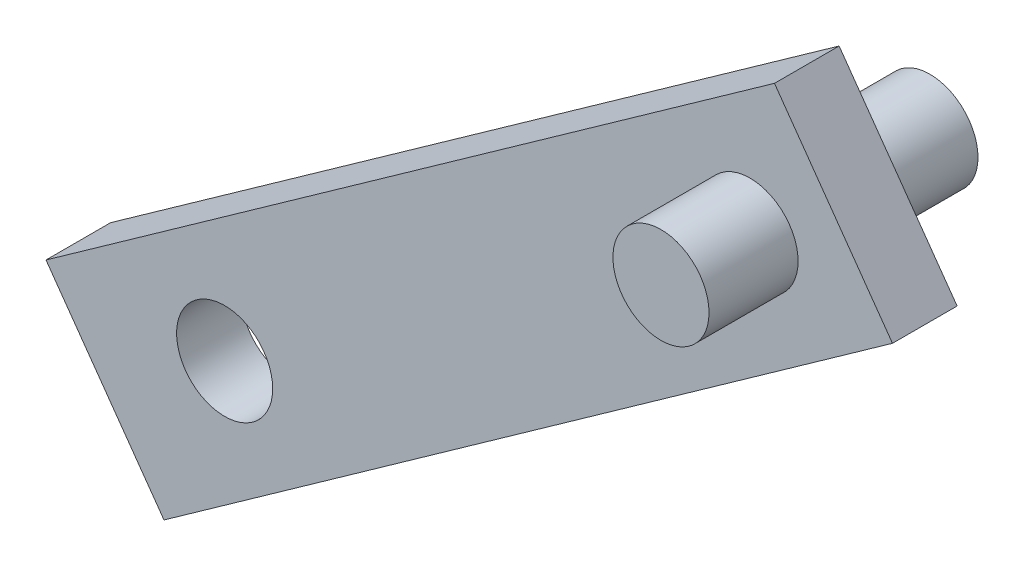
from build123d import *

# Parameters (mm, degrees)
SKETCH1_R                = 1.27
BOSS_EXTRUDE6_DEPTH      = 1.70891122
BOSS_EXTRUDE7_DEPTH      = 4.064
BOSS_EXTRUDE7_DEPTH_BACK = 3.048
SKETCH1_8_R              = 1.27


with BuildPart() as part:
    # Sketch1 → Boss-Extrude6 (new body)
    with BuildSketch(Plane.XY):
        Polygon((-36.430695542, -6.363620451), (-33.310929263, -10.757657465), (-14.0499524, 2.917636108), (-17.16971868, 7.311673121), align=None)
        with Locations((-31.707269185, -6.314523273)):
            Circle(SKETCH1_R, mode=Mode.SUBTRACT)
    extrude(amount=BOSS_EXTRUDE6_DEPTH)

    # Sketch1_8 → Boss-Extrude7 (add, two sides: drawn at the far end of the back side and taken through both)
    with BuildSketch(Plane.XY.offset(-BOSS_EXTRUDE7_DEPTH_BACK)):
        with Locations((-17.815528052, 3.548612931)):
            Circle(SKETCH1_8_R)
    extrude(amount=BOSS_EXTRUDE7_DEPTH + BOSS_EXTRUDE7_DEPTH_BACK)


solid = part.part
